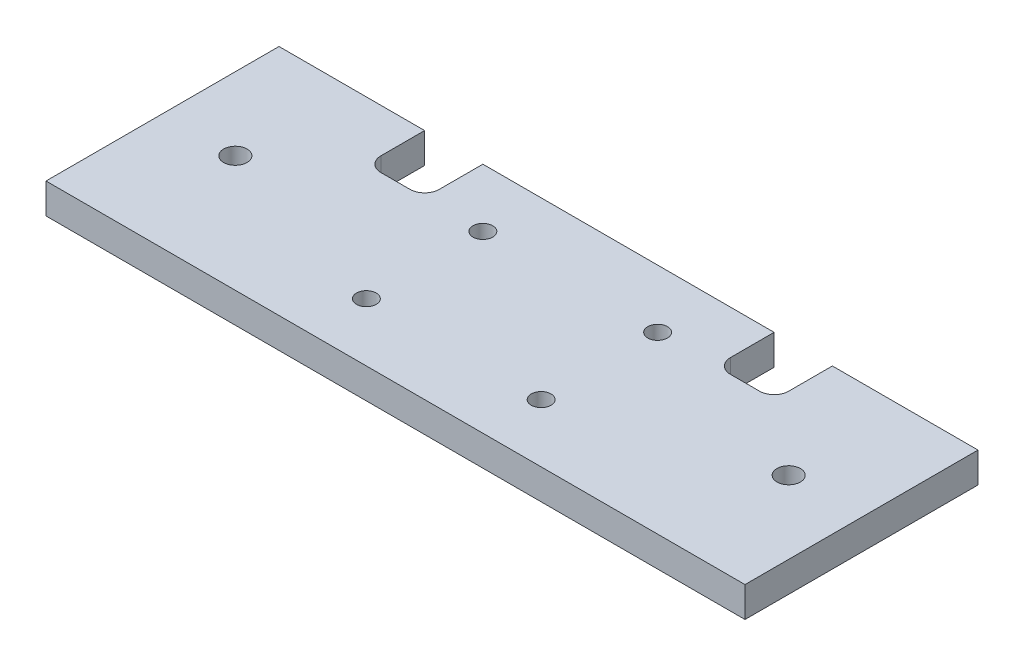
from build123d import *

# Parameters (mm, degrees)
SKETCH1_W                   = 152.4
SKETCH1_H                   = 50.8
BOSS_EXTRUDE1_DEPTH         = 6.604
CUT_EXTRUDE1_DEPTH          = 7.604
F_1_4_20_TAPPED_HOLE1_D     = 5.1054
F_1_4_20_TAPPED_HOLE1_DEPTH = 16.51
F_1_4_20_TAPPED_HOLE1_TIP   = 1.533816902
F_8_CLEARANCE_HOLE1_D       = 4.3053
F_8_CLEARANCE_HOLE1_DEPTH   = 7.62
F_8_CLEARANCE_HOLE1_TIP     = 1.293442612


with BuildPart() as part:
    # Sketch1 → Boss-Extrude1 (new body)
    with BuildSketch(Plane(origin=(0, 0, 0), x_dir=(1, 0, 0), z_dir=(0, 1, 0))):
        Rectangle(SKETCH1_W, SKETCH1_H)
    extrude(amount=BOSS_EXTRUDE1_DEPTH)

    # Sketch2 → Cut-Extrude1 (cut, through all)
    with BuildSketch(Plane(origin=(0, 6.604, 0), x_dir=(1, 0, 0), z_dir=(0, 1, 0))):
        with BuildLine():
            Line((-44.45, 25.4), (-31.75, 25.4))
            Line((-31.75, 25.4), (-31.75, 15.875))
            ThreePointArc((-31.75, 15.875), (-32.67993597, 13.62993597), (-34.925, 12.7))
            Line((-34.925, 12.7), (-41.275, 12.7))
            ThreePointArc((-41.275, 12.7), (-43.52006403, 13.62993597), (-44.45, 15.875))
            Line((-44.45, 15.875), (-44.45, 25.4))
        make_face()
    cut_extrude1 = extrude(amount=-CUT_EXTRUDE1_DEPTH, mode=Mode.SUBTRACT)

    # Mirror1: Cut-Extrude1 across plane
    add(cut_extrude1.mirror(Plane(origin=(0, 0, 0), x_dir=(0, 0, 1), z_dir=(1, 0, 0))), mode=Mode.SUBTRACT)

    # 1/4-20 Tapped Hole1
    with Locations(Plane(origin=(0, 6.604, 0), x_dir=(1, 0, 0), z_dir=(0, 1, 0))):
        with Locations((-60.325, 0), (60.325, 0)):
            Hole(F_1_4_20_TAPPED_HOLE1_D / 2, depth=F_1_4_20_TAPPED_HOLE1_DEPTH)
            with Locations((0, 0, -(F_1_4_20_TAPPED_HOLE1_DEPTH + F_1_4_20_TAPPED_HOLE1_TIP / 2))):  # 118° drill point
                Cone(0, F_1_4_20_TAPPED_HOLE1_D / 2, F_1_4_20_TAPPED_HOLE1_TIP, mode=Mode.SUBTRACT)

    # #8 Clearance Hole1
    with Locations(Plane(origin=(0, 6.604, 0), x_dir=(1, 0, 0), z_dir=(0, 1, 0))):
        with Locations((-19.05, 12.7), (-19.05, -12.7), (19.05, 12.7), (19.05, -12.7)):
            Hole(F_8_CLEARANCE_HOLE1_D / 2, depth=F_8_CLEARANCE_HOLE1_DEPTH)
            with Locations((0, 0, -(F_8_CLEARANCE_HOLE1_DEPTH + F_8_CLEARANCE_HOLE1_TIP / 2))):  # 118° drill point
                Cone(0, F_8_CLEARANCE_HOLE1_D / 2, F_8_CLEARANCE_HOLE1_TIP, mode=Mode.SUBTRACT)


solid = part.part
